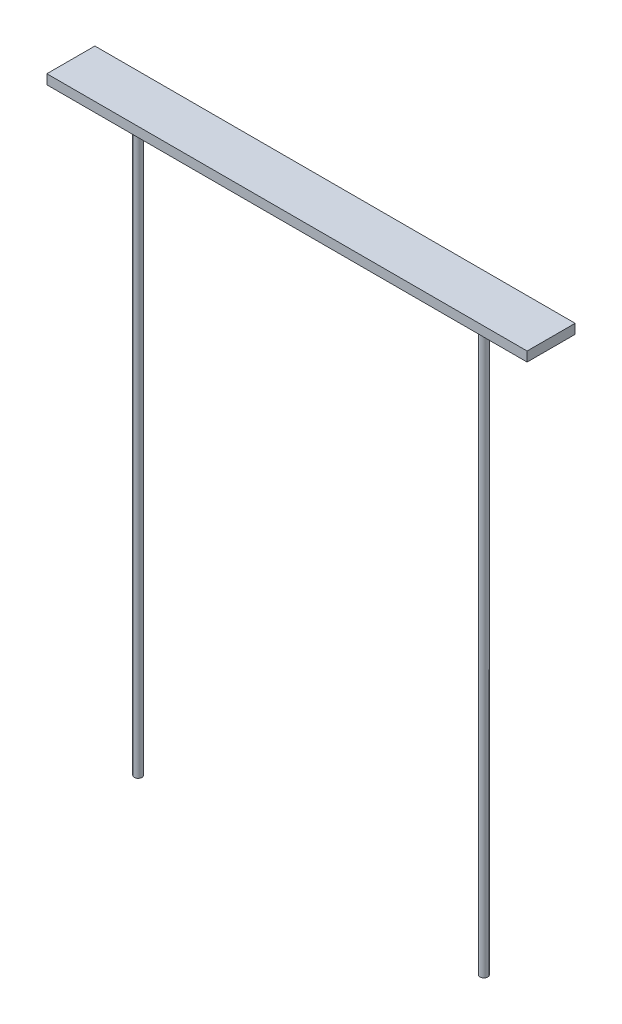
from build123d import *

# Parameters (mm, degrees)
SKETCH1_W           = 500
SKETCH1_H           = 50
BOSS_EXTRUDE1_DEPTH = 10
SKETCH2_R           = 4
BOSS_EXTRUDE2_DEPTH = 600
SKETCH6_R           = 4
BOSS_EXTRUDE3_DEPTH = 600


with BuildPart() as part:
    # Sketch1 → Boss-Extrude1 (new body)
    with BuildSketch(Plane(origin=(0, 0, 0), x_dir=(1, 0, 0), z_dir=(0, 1, 0))):
        Rectangle(SKETCH1_W, SKETCH1_H)
    extrude(amount=BOSS_EXTRUDE1_DEPTH)

    # Sketch2 → Boss-Extrude2 (add)
    with BuildSketch(Plane.XZ):
        with Locations((180, 0)):
            Circle(SKETCH2_R)
    extrude(amount=BOSS_EXTRUDE2_DEPTH)

    # Sketch6 → Boss-Extrude3 (add)
    with BuildSketch(Plane.XZ):
        with Locations((-180, 0)):
            Circle(SKETCH6_R)
    extrude(amount=BOSS_EXTRUDE3_DEPTH)


solid = part.part
